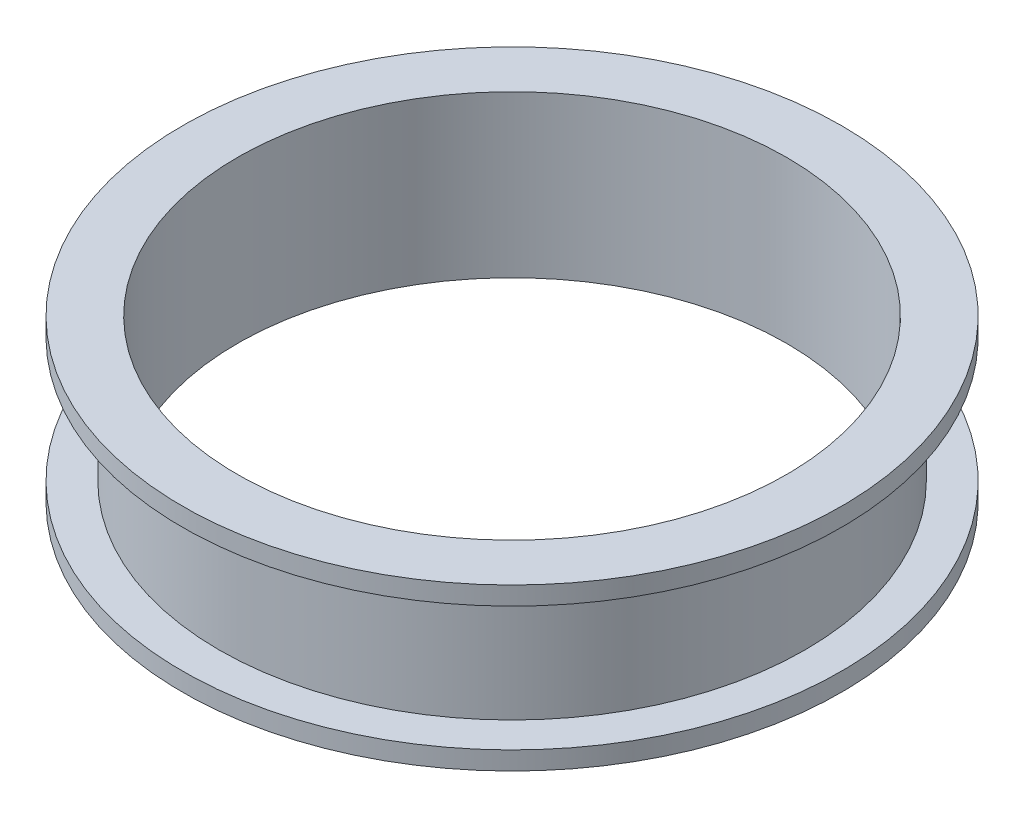
from build123d import *

# Parameters (mm, degrees)
CUT_EXTRUDE1_REACH = 4.5
SKETCH2_R          = 37.5


with BuildPart() as part:
    # Sketch1 → Revolve1 (revolve)
    with BuildSketch(Plane.XY):
        Polygon((0, 0), (37.5, 0), (37.5, 19.5), (45, 19.5), (45, 17), (40, 17), (40, 0), (45, 0), (45, -2.5), (0, -2.5), align=None)
    revolve(axis=Axis((0, -2.5, 0), (0, 1, 0)))

    # Sketch2 → Cut-Extrude1 (cut, up to next)
    with BuildSketch(Plane(origin=(0, 0, 0), x_dir=(1, 0, 0), z_dir=(0, 1, 0)), mode=Mode.PRIVATE) as cut_extrude1_sk1:
        Circle(SKETCH2_R)
    cut_extrude1_tool1 = extrude(cut_extrude1_sk1.sketch, amount=-CUT_EXTRUDE1_REACH, mode=Mode.PRIVATE) & part.part
    add(cut_extrude1_tool1.solids().sort_by_distance((0, 0, 0))[0], mode=Mode.SUBTRACT)


solid = part.part
